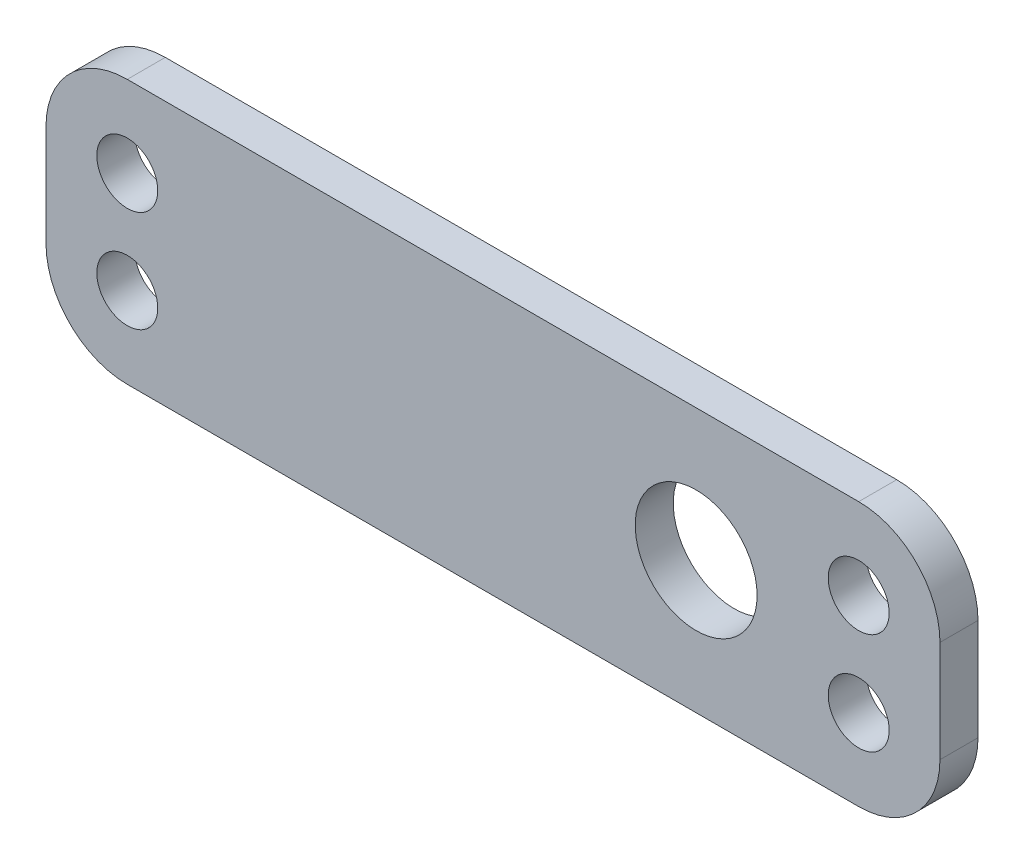
from build123d import *

# Parameters (mm, degrees)
SKETCH1_W           = 69.85
SKETCH1_H           = 20.6375
SKETCH1_R           = 2.38125
BOSS_EXTRUDE1_DEPTH = 2.9718
FILLET1_R           = 6.35
SKETCH2_R           = 4.7625
CUT_EXTRUDE1_DEPTH  = 3.9718


with BuildPart() as part:
    # Sketch1 → Boss-Extrude1 (new body)
    with BuildSketch(Plane.XY):
        Rectangle(SKETCH1_W, SKETCH1_H)
        with Locations((-28.575, 3.96875)):
            Circle(SKETCH1_R, mode=Mode.SUBTRACT)
        with Locations((-28.575, -3.96875)):
            Circle(SKETCH1_R, mode=Mode.SUBTRACT)
        with Locations((28.575, 3.96875)):
            Circle(SKETCH1_R, mode=Mode.SUBTRACT)
        with Locations((28.575, -3.96875)):
            Circle(SKETCH1_R, mode=Mode.SUBTRACT)
    extrude(amount=BOSS_EXTRUDE1_DEPTH)

    # Fillet1
    fillet1_edges = [part.edges().sort_by_distance(p)[0] for p in [
        (-34.925, 10.31875, 1.4859),
        (34.925, 10.31875, 1.4859),
        (34.925, -10.31875, 1.4859),
        (-34.925, -10.31875, 1.4859),
    ]]
    fillet(fillet1_edges, radius=FILLET1_R)

    # Sketch2 → Cut-Extrude1 (cut, through all)
    with BuildSketch(Plane.XY.offset(2.9718)):
        with Locations((15.875, 0)):
            Circle(SKETCH2_R)
    extrude(amount=-CUT_EXTRUDE1_DEPTH, mode=Mode.SUBTRACT)


solid = part.part
